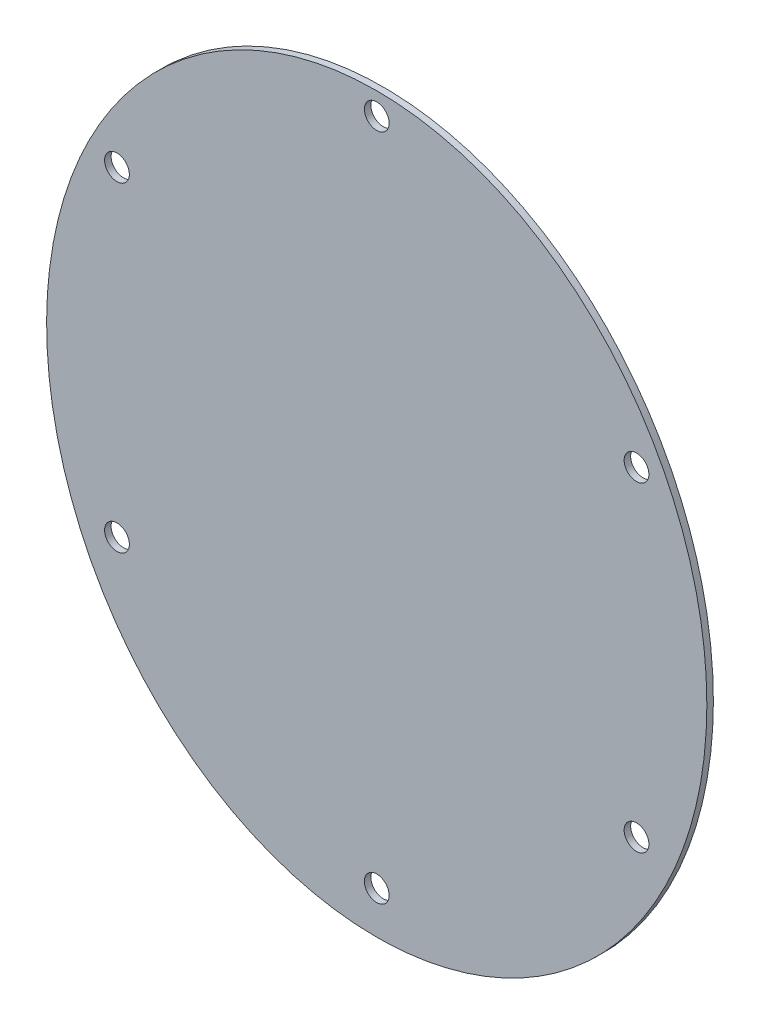
from build123d import *

# Parameters (mm, degrees)
BOSS_EXTRUDE1_DEPTH   = 1
F_6_CLEARANCE_HOLE1_D = 3.7973


with BuildPart() as part:
    # Sketch2 → Boss-Extrude1 (new body)
    with BuildSketch(Plane.XY):
        with BuildLine():
            add(Edge.make_bspline(
                [(-0.098219478, -59.504960496), (3.436897561, -59.512574482), (6.902385574, -59.113542237), (12.00163576, -57.936921899), (13.684799406, -57.447571682), (17.01696053, -56.270438132), (18.634612927, -55.593764311), (23.350610632, -53.314567678), (26.314073008, -51.46447424), (31.882951557, -47.12160545), (34.399299567, -44.698764298), (37.808190417, -40.721626254), (38.883032168, -39.338283004), (40.403372211, -37.177066293), (40.893875715, -36.443472131), (41.835475697, -34.961682866), (42.287708493, -34.2119014), (44.458849611, -30.419906345), (45.90953731, -27.24931407), (47.671839201, -22.295401849), (48.191615054, -20.604334077), (49.075199253, -17.210830482), (49.441286028, -15.503804837), (50.322613559, -10.353288309), (50.620720413, -6.880330536), (50.626013179, -2.489282098), (50.608572779, -1.606657759), (50.53662485, 0.149624336), (50.37333489, 2.773285261), (50.04580771, 5.365022426), (49.176634833, 10.506877272), (48.311997128, 13.879346606), (46.852474957, 18.021318247), (46.540801081, 18.847888508), (45.884393662, 20.478127951), (45.539289659, 21.283060371), (44.453460732, 23.667406618), (43.662215028, 25.216367103), (41.088011362, 29.742409642), (39.105254571, 32.599055274), (36.259966059, 35.948733888), (35.671080887, 36.608999569), (34.469046359, 37.891487052), (33.854615044, 38.515316601), (31.971096091, 40.334584926), (30.661776584, 41.477794476), (27.936115294, 43.625276685), (26.519464998, 44.62914883), (24.310238358, 46.025581696), (23.559761765, 46.472796538), (22.029691758, 47.329426608), (21.248305297, 47.739683753), (17.285661626, 49.682954527), (14.00765298, 50.863255982), (8.929001037, 52.0729348), (7.209032332, 52.382196161), (4.586415661, 52.698075517), (3.703429851, 52.778602256), (1.947001053, 52.887584039), (1.070792684, 52.916474811), (-3.300409503, 52.935359105), (-6.766182641, 52.552450553), (-11.059069639, 51.571909237), (-11.917186291, 51.349987666), (-13.608240345, 50.860915408), (-14.443658358, 50.593322204), (-16.920492094, 49.723439489), (-18.532519195, 49.054119139), (-21.680381495, 47.541696652), (-23.216502951, 46.699247424), (-25.463058735, 45.304136794), (-26.201985439, 44.817175832), (-27.644413593, 43.811097409), (-28.350082581, 43.290681866), (-31.803770535, 40.605152436), (-34.328117371, 38.190017416), (-37.197557306, 34.851414441), (-37.757689344, 34.166650306), (-38.8385265, 32.778419928), (-39.360600883, 32.073473438), (-40.87358044, 29.927196367), (-41.811263511, 28.454440878), (-43.549814588, 25.428147651), (-44.351144374, 23.874882571), (-45.450758837, 21.484534709), (-45.800228369, 20.677673946), (-46.464946153, 19.043746517), (-46.778638512, 18.220393765), (-48.251656367, 14.086774621), (-49.130626655, 10.711540313), (-50.019665398, 5.550687541), (-50.24444942, 3.81407138), (-50.471014482, 1.183903546), (-50.528035221, 0.302196196), (-50.604282959, -1.453716399), (-50.623719259, -2.329854837), (-50.629816849, -6.701686712), (-50.343410551, -10.170817116), (-49.475529335, -15.331879221), (-49.113284607, -17.045136846), (-48.454343975, -19.603780705), (-48.21552344, -20.453924473), (-47.70399006, -22.133572475), (-47.430761413, -22.96516725), (-45.978832083, -27.082713054), (-44.543033628, -30.247502648), (-41.961585357, -34.793102732), (-41.029976364, -36.274783385), (-39.517329037, -38.442998574), (-38.994293998, -39.155828142), (-37.92165514, -40.546535368), (-37.370622739, -41.226511572), (-34.542992957, -44.550652164), (-32.049200166, -46.967812592), (-28.624332781, -49.667744315), (-27.923878427, -50.191550667), (-26.490792265, -51.20553278), (-25.756352373, -51.696833094), (-23.515297982, -53.110508305), (-21.985194241, -53.96426979), (-17.288093174, -56.262961801), (-14.01546581, -57.448151806), (-9.735563333, -58.464604177), (-8.86764039, -58.644870167), (-7.127462632, -58.953940787), (-6.254828129, -59.083022027), (-4.50450795, -59.290677091), (-3.62681671, -59.369195272), (-1.866349861, -59.47539228), (-0.981998738, -59.503056999), (-0.098219478, -59.504960496)],
                knots=[0, 0, 0, 0, 0.03125, 0.03125, 0.046875, 0.046875, 0.0625, 0.0625, 0.09375, 0.09375, 0.125, 0.125, 0.140625, 0.140625, 0.1484375, 0.1484375, 0.15625, 0.15625, 0.1875, 0.1875, 0.203125, 0.203125, 0.21875, 0.21875, 0.25, 0.25, 0.2578125, 0.2578125, 0.265625, 0.28125, 0.28125, 0.3125, 0.3125, 0.3203125, 0.3203125, 0.328125, 0.328125, 0.34375, 0.34375, 0.375, 0.375, 0.3828125, 0.3828125, 0.390625, 0.390625, 0.40625, 0.40625, 0.421875, 0.421875, 0.4296875, 0.4296875, 0.4375, 0.4375, 0.46875, 0.46875, 0.484375, 0.484375, 0.4921875, 0.4921875, 0.5, 0.5, 0.53125, 0.53125, 0.5390625, 0.5390625, 0.546875, 0.546875, 0.5625, 0.5625, 0.578125, 0.578125, 0.5859375, 0.5859375, 0.59375, 0.59375, 0.625, 0.625, 0.6328125, 0.6328125, 0.640625, 0.640625, 0.65625, 0.65625, 0.671875, 0.671875, 0.6796875, 0.6796875, 0.6875, 0.6875, 0.71875, 0.71875, 0.734375, 0.734375, 0.7421875, 0.7421875, 0.75, 0.75, 0.78125, 0.78125, 0.796875, 0.796875, 0.8046875, 0.8046875, 0.8125, 0.8125, 0.84375, 0.84375, 0.859375, 0.859375, 0.8671875, 0.8671875, 0.875, 0.875, 0.90625, 0.90625, 0.9140625, 0.9140625, 0.921875, 0.921875, 0.9375, 0.9375, 0.96875, 0.96875, 0.9765625, 0.9765625, 0.984375, 0.984375, 0.9921875, 0.9921875, 1, 1, 1, 1], degree=3))
        make_face()
    extrude(amount=BOSS_EXTRUDE1_DEPTH)

    # #6 Clearance Hole1 (through all)
    with Locations(Plane.XY.offset(1)):
        with Locations((0, 49.535898385), (39.837168574, 22.828093358), (-39.837168574, 22.828093358), (-39.837168574, -26.292194973), (0, -53), (39.837168574, -26.292194973)):
            Hole(F_6_CLEARANCE_HOLE1_D / 2)


solid = part.part
